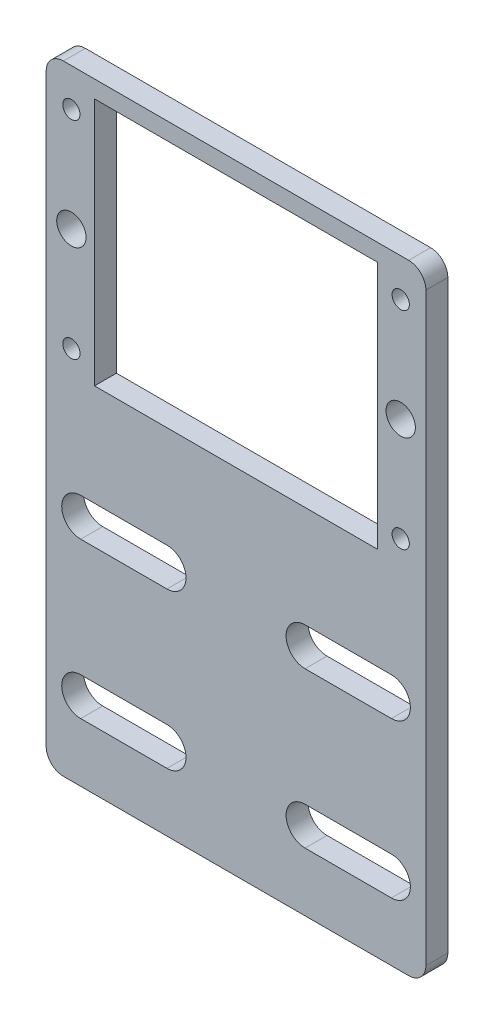
from build123d import *

# Parameters (mm, degrees)
SKETCH1_W           = 110
SKETCH1_H           = 82
BOSS_EXTRUDE1_DEPTH = 6.35
CUT_EXTRUDE1_REACH  = 8.35
SKETCH2_W           = 82
SKETCH2_H           = 72
SKETCH3_W           = 110
SKETCH3_H           = 97.464272111
BOSS_EXTRUDE2_DEPTH = 6.35
CUT_EXTRUDE2_REACH  = 8.35
FILLET1_R           = 5
CUT_EXTRUDE3_REACH  = 8.35
SKETCH5_R           = 2.5019
SKETCH5_R_2         = 4.25


with BuildPart() as part:
    # Sketch1 → Boss-Extrude1 (new body)
    with BuildSketch(Plane.XY):
        with Locations((55, 41)):
            Rectangle(SKETCH1_W, SKETCH1_H)
    extrude(amount=BOSS_EXTRUDE1_DEPTH)

    # Sketch2 → Cut-Extrude1 (cut, up to next)
    with BuildSketch(Plane.XY.offset(6.35), mode=Mode.PRIVATE) as cut_extrude1_sk1:
        with Locations((55, 41)):
            Rectangle(SKETCH2_W, SKETCH2_H)
    cut_extrude1_tool1 = extrude(cut_extrude1_sk1.sketch, amount=-CUT_EXTRUDE1_REACH, mode=Mode.PRIVATE) & part.part
    add(cut_extrude1_tool1.solids().sort_by_distance((55, 41, 6.35))[0], mode=Mode.SUBTRACT)

    # Sketch3 → Boss-Extrude2 (add)
    with BuildSketch(Plane.XY.offset(6.35)):
        with Locations((55, -48.732136055)):
            Rectangle(SKETCH3_W, SKETCH3_H)
    extrude(amount=-BOSS_EXTRUDE2_DEPTH)

    # Sketch4 → Cut-Extrude2 (cut, up to next)
    with BuildSketch(Plane.XY.offset(6.35), mode=Mode.PRIVATE) as cut_extrude2_sk1:
        with BuildLine():
            Line((10, -69.464272111), (35, -69.464272111))
            ThreePointArc((35, -69.464272111), (40.5, -74.964272111), (35, -80.464272111))
            Line((35, -80.464272111), (10, -80.464272111))
            ThreePointArc((10, -80.464272111), (4.5, -74.964272111), (10, -69.464272111))
        make_face()
    cut_extrude2_tool1 = extrude(cut_extrude2_sk1.sketch, amount=-CUT_EXTRUDE2_REACH, mode=Mode.PRIVATE) & part.part
    add(cut_extrude2_tool1.solids().sort_by_distance((22.5, -74.964272, 6.35))[0], mode=Mode.SUBTRACT)
    # Sketch4 → Cut-Extrude2 (cut, up to next)
    with BuildSketch(Plane.XY.offset(6.35), mode=Mode.PRIVATE) as cut_extrude2_sk2:
        with BuildLine():
            Line((100, -69.464272111), (75, -69.464272111))
            ThreePointArc((75, -69.464272111), (69.5, -74.964272111), (75, -80.464272111))
            Line((75, -80.464272111), (100, -80.464272111))
            ThreePointArc((100, -80.464272111), (105.5, -74.964272111), (100, -69.464272111))
        make_face()
    cut_extrude2_tool2 = extrude(cut_extrude2_sk2.sketch, amount=-CUT_EXTRUDE2_REACH, mode=Mode.PRIVATE) & part.part
    add(cut_extrude2_tool2.solids().sort_by_distance((87.5, -74.964272, 6.35))[0], mode=Mode.SUBTRACT)
    # Sketch4 → Cut-Extrude2 (cut, up to next)
    with BuildSketch(Plane.XY.offset(6.35), mode=Mode.PRIVATE) as cut_extrude2_sk3:
        with BuildLine():
            Line((10, -35.464272111), (35, -35.464272111))
            ThreePointArc((35, -35.464272111), (40.5, -29.964272111), (35, -24.464272111))
            Line((35, -24.464272111), (10, -24.464272111))
            ThreePointArc((10, -24.464272111), (4.5, -29.964272111), (10, -35.464272111))
        make_face()
    cut_extrude2_tool3 = extrude(cut_extrude2_sk3.sketch, amount=-CUT_EXTRUDE2_REACH, mode=Mode.PRIVATE) & part.part
    add(cut_extrude2_tool3.solids().sort_by_distance((22.5, -29.964272, 6.35))[0], mode=Mode.SUBTRACT)
    # Sketch4 → Cut-Extrude2 (cut, up to next)
    with BuildSketch(Plane.XY.offset(6.35), mode=Mode.PRIVATE) as cut_extrude2_sk4:
        with BuildLine():
            Line((100, -35.464272111), (75, -35.464272111))
            ThreePointArc((75, -35.464272111), (69.5, -29.964272111), (75, -24.464272111))
            Line((75, -24.464272111), (100, -24.464272111))
            ThreePointArc((100, -24.464272111), (105.5, -29.964272111), (100, -35.464272111))
        make_face()
    cut_extrude2_tool4 = extrude(cut_extrude2_sk4.sketch, amount=-CUT_EXTRUDE2_REACH, mode=Mode.PRIVATE) & part.part
    add(cut_extrude2_tool4.solids().sort_by_distance((87.5, -29.964272, 6.35))[0], mode=Mode.SUBTRACT)

    # Fillet1
    fillet1_edges = [part.edges().sort_by_distance(p)[0] for p in [
        (110, -97.464272111, 3.175),
        (0, -97.464272111, 3.175),
        (0, 82, 3.175),
        (110, 82, 3.175),
    ]]
    fillet(fillet1_edges, radius=FILLET1_R)

    # Sketch5 → Cut-Extrude3 (cut, up to next)
    with BuildSketch(Plane.XY.offset(6.35), mode=Mode.PRIVATE) as cut_extrude3_sk1:
        with Locations((7.2988, 11.0026)):
            Circle(SKETCH5_R)
    cut_extrude3_tool1 = extrude(cut_extrude3_sk1.sketch, amount=-CUT_EXTRUDE3_REACH, mode=Mode.PRIVATE) & part.part
    add(cut_extrude3_tool1.solids().sort_by_distance((7.2988, 11.0026, 6.35))[0], mode=Mode.SUBTRACT)
    # Sketch5 → Cut-Extrude3 (cut, up to next)
    with BuildSketch(Plane.XY.offset(6.35), mode=Mode.PRIVATE) as cut_extrude3_sk2:
        with Locations((7.2988, 70.9974)):
            Circle(SKETCH5_R)
    cut_extrude3_tool2 = extrude(cut_extrude3_sk2.sketch, amount=-CUT_EXTRUDE3_REACH, mode=Mode.PRIVATE) & part.part
    add(cut_extrude3_tool2.solids().sort_by_distance((7.2988, 70.9974, 6.35))[0], mode=Mode.SUBTRACT)
    # Sketch5 → Cut-Extrude3 (cut, up to next)
    with BuildSketch(Plane.XY.offset(6.35), mode=Mode.PRIVATE) as cut_extrude3_sk3:
        with Locations((102.7012, 70.9974)):
            Circle(SKETCH5_R)
    cut_extrude3_tool3 = extrude(cut_extrude3_sk3.sketch, amount=-CUT_EXTRUDE3_REACH, mode=Mode.PRIVATE) & part.part
    add(cut_extrude3_tool3.solids().sort_by_distance((102.7012, 70.9974, 6.35))[0], mode=Mode.SUBTRACT)
    # Sketch5 → Cut-Extrude3 (cut, up to next)
    with BuildSketch(Plane.XY.offset(6.35), mode=Mode.PRIVATE) as cut_extrude3_sk4:
        with Locations((102.7012, 11.0026)):
            Circle(SKETCH5_R)
    cut_extrude3_tool4 = extrude(cut_extrude3_sk4.sketch, amount=-CUT_EXTRUDE3_REACH, mode=Mode.PRIVATE) & part.part
    add(cut_extrude3_tool4.solids().sort_by_distance((102.7012, 11.0026, 6.35))[0], mode=Mode.SUBTRACT)
    # Sketch5 → Cut-Extrude3 (cut, up to next)
    with BuildSketch(Plane.XY.offset(6.35), mode=Mode.PRIVATE) as cut_extrude3_sk5:
        with Locations((7.2988, 41)):
            Circle(SKETCH5_R_2)
    cut_extrude3_tool5 = extrude(cut_extrude3_sk5.sketch, amount=-CUT_EXTRUDE3_REACH, mode=Mode.PRIVATE) & part.part
    add(cut_extrude3_tool5.solids().sort_by_distance((7.2988, 41, 6.35))[0], mode=Mode.SUBTRACT)
    # Sketch5 → Cut-Extrude3 (cut, up to next)
    with BuildSketch(Plane.XY.offset(6.35), mode=Mode.PRIVATE) as cut_extrude3_sk6:
        with Locations((102.7012, 41)):
            Circle(SKETCH5_R_2)
    cut_extrude3_tool6 = extrude(cut_extrude3_sk6.sketch, amount=-CUT_EXTRUDE3_REACH, mode=Mode.PRIVATE) & part.part
    add(cut_extrude3_tool6.solids().sort_by_distance((102.7012, 41, 6.35))[0], mode=Mode.SUBTRACT)


solid = part.part
